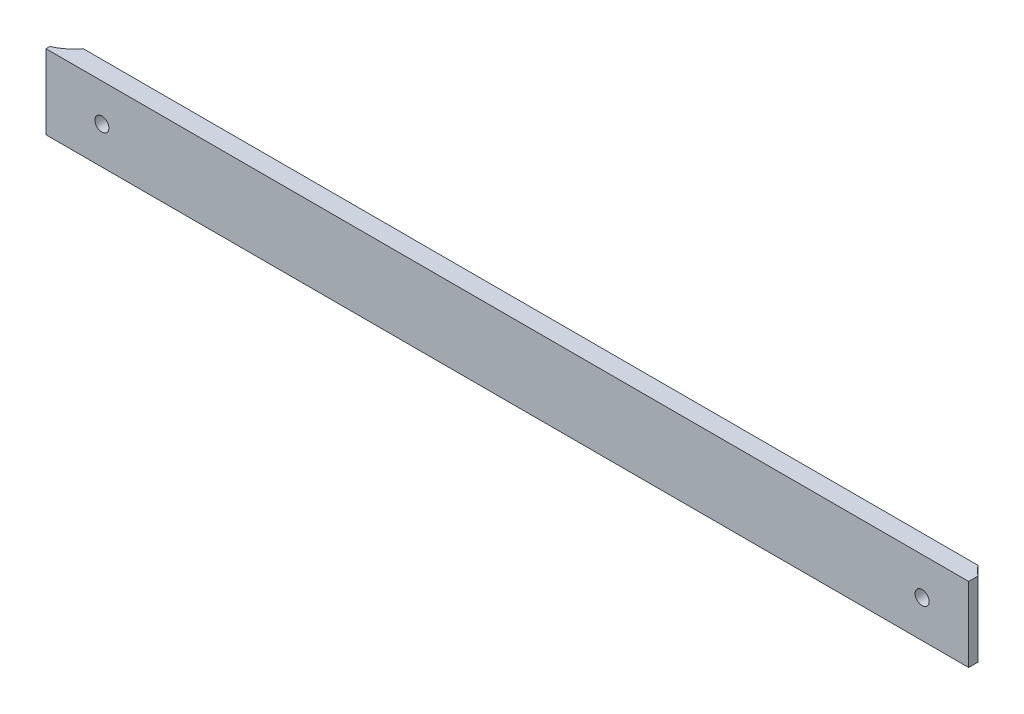
from build123d import *

# Parameters (mm, degrees)
BASE_DEPTH                     = 12.7
F_3_16_0_1875_DIAMETER_HOLE1_D = 4.7625


with BuildPart() as part:
    # Sketch1 → Base (new body, symmetric)
    with BuildSketch(Plane(origin=(0, 0, 0), x_dir=(1, 0, 0), z_dir=(0, 1, 0))):
        with BuildLine():
            Line((-152.4, -9.525), (152.4, -9.525))
            ThreePointArc((152.4, -9.525), (153.874679849, -11.225320151), (155.575, -12.7))
            Line((155.575, -12.7), (155.575, -15.875))
            Line((155.575, -15.875), (-158.75, -15.875))
            Line((-158.75, -15.875), (-158.75, -14.549677831))
            ThreePointArc((-158.75, -14.549677831), (-155.249240038, -12.449022177), (-152.4, -9.525))
        make_face()
    extrude(amount=BASE_DEPTH, both=True)

    # 3/16 (0.1875) Diameter Hole1 (through all)
    with Locations(Plane.XY.offset(15.875)):
        with Locations((-139.7, 0), (139.7, 0)):
            Hole(F_3_16_0_1875_DIAMETER_HOLE1_D / 2)


solid = part.part
